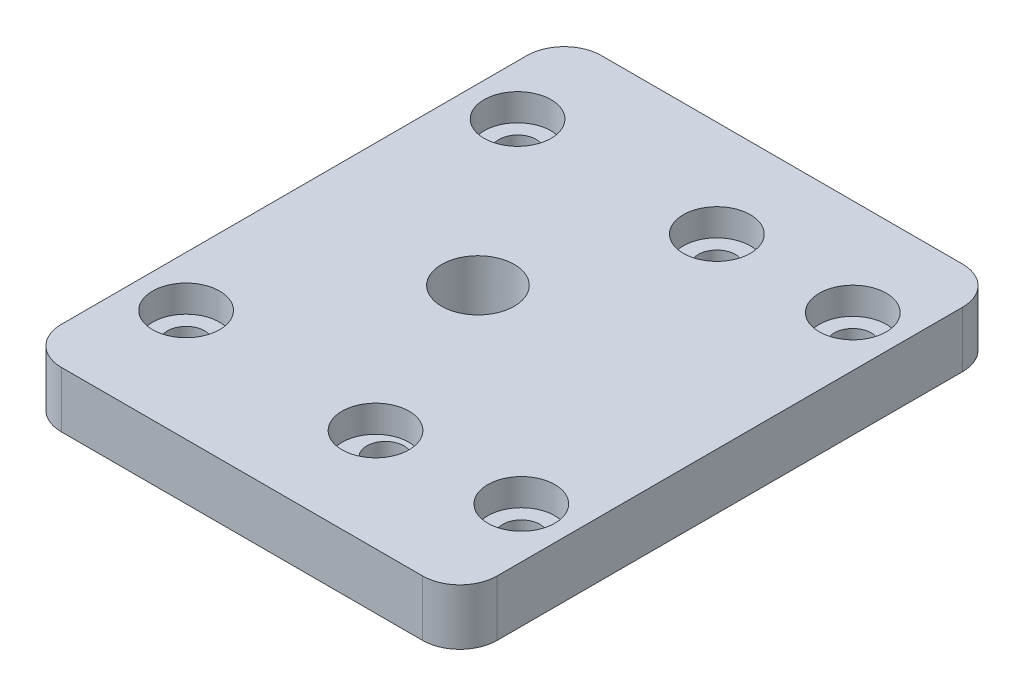
from build123d import *

# Parameters (mm, degrees)
SKETCH1_W           = 23.4
SKETCH1_H           = 29
SKETCH1_R           = 1
BOSS_EXTRUDE1_DEPTH = 3
FILLET1_R           = 2
SKETCH8_R           = 1
CUT_EXTRUDE5_DEPTH  = 10
SKETCH10_R          = 1.95
CUT_EXTRUDE6_DEPTH  = 10
SKETCH11_R          = 1.8
CUT_EXTRUDE7_DEPTH  = 1.45


with BuildPart() as part:
    # Sketch1 → Boss-Extrude1 (new body)
    with BuildSketch(Plane(origin=(0, 0, 0), x_dir=(1, 0, 0), z_dir=(0, 1, 0))):
        Rectangle(SKETCH1_W, SKETCH1_H)
        with Locations((9, 9.3)):
            Circle(SKETCH1_R, mode=Mode.SUBTRACT)
        with Locations((9, -8.5)):
            Circle(SKETCH1_R, mode=Mode.SUBTRACT)
        with Locations((-9, -8.5)):
            Circle(SKETCH1_R, mode=Mode.SUBTRACT)
        with Locations((1.7, -8.5)):
            Circle(SKETCH1_R, mode=Mode.SUBTRACT)
    extrude(amount=BOSS_EXTRUDE1_DEPTH)

    # Fillet1
    fillet1_edges = [part.edges().sort_by_distance(p)[0] for p in [
        (11.7, 1.5, 14.5),
        (-11.7, 1.5, 14.5),
        (-11.7, 1.5, -14.5),
        (11.7, 1.5, -14.5),
    ]]
    fillet(fillet1_edges, radius=FILLET1_R)

    # Sketch8 → Cut-Extrude5 (cut)
    with BuildSketch(Plane(origin=(0, 3, 0), x_dir=(1, 0, 0), z_dir=(0, 1, 0))):
        with Locations((1.7, 9.3)):
            Circle(SKETCH8_R)
        with Locations((-9, 9.3)):
            Circle(SKETCH8_R)
    extrude(amount=-CUT_EXTRUDE5_DEPTH, mode=Mode.SUBTRACT)

    # Sketch10 → Cut-Extrude6 (cut)
    with BuildSketch(Plane(origin=(0, 3, 0), x_dir=(1, 0, 0), z_dir=(0, 1, 0))):
        with Locations((-2.328177417, 0.5)):
            Circle(SKETCH10_R)
    extrude(amount=-CUT_EXTRUDE6_DEPTH, mode=Mode.SUBTRACT)

    # Sketch11 → Cut-Extrude7 (cut)
    with BuildSketch(Plane(origin=(0, 3, 0), x_dir=(1, 0, 0), z_dir=(0, 1, 0))):
        with Locations((-9, -8.5)):
            Circle(SKETCH11_R)
        with Locations((1.671822583, -9)):
            Circle(SKETCH11_R)
        with Locations((9, -8.5)):
            Circle(SKETCH11_R)
        with Locations((9, 9.3)):
            Circle(SKETCH11_R)
        with Locations((1.7, 9.3)):
            Circle(SKETCH11_R)
        with Locations((-9, 9.3)):
            Circle(SKETCH11_R)
    extrude(amount=-CUT_EXTRUDE7_DEPTH, mode=Mode.SUBTRACT)


solid = part.part
